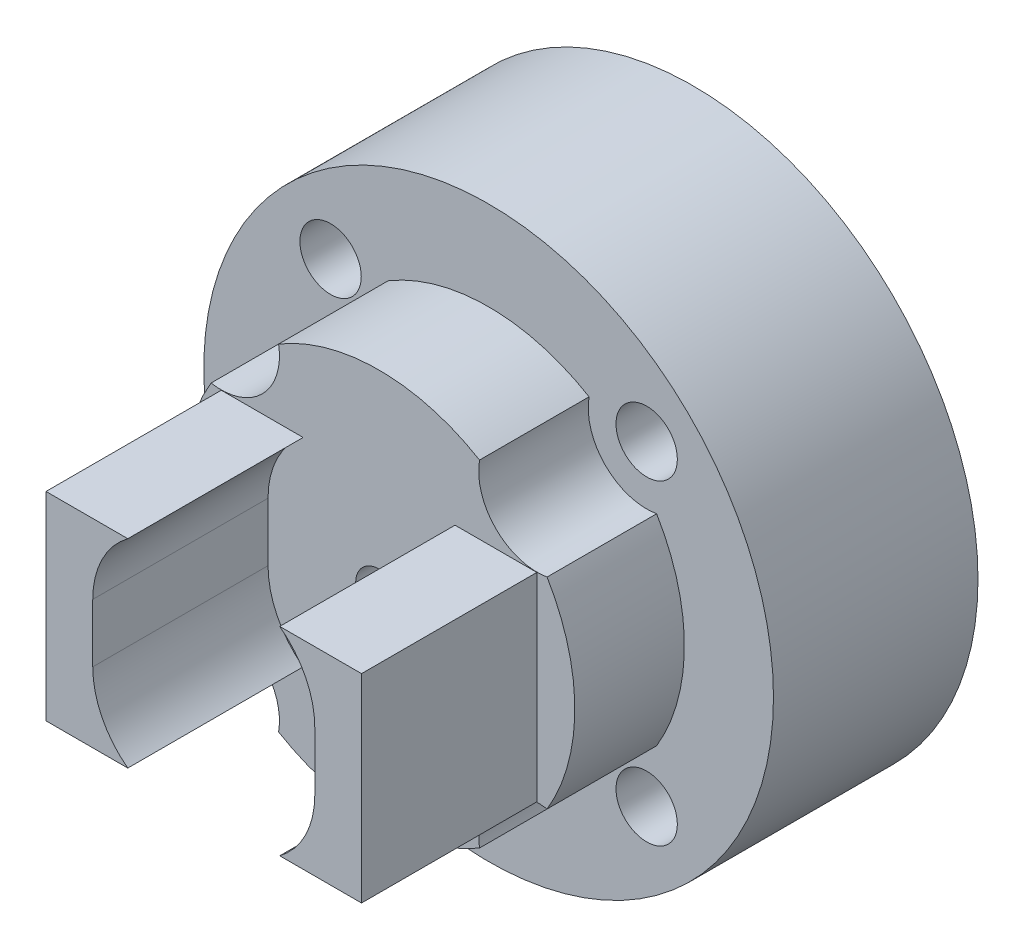
from build123d import *

# Parameters (mm, degrees)
SKIZZE1_R                       = 6.7
AUFSATZ_LINEAR_AUSTRAGEN1_DEPTH = 3.75
SKIZZE1_7_R                     = 9.75
SKIZZE1_7_R_2                   = 3.55
AUFSATZ_LINEAR_AUSTRAGEN2_DEPTH = 7
SKIZZE5_R                       = 1.05
SCHNITT_LINEAR_AUSTRAGEN1_DEPTH = 11.75
SKIZZE5_3_R                     = 2
SKIZZE5_3_R_2                   = 1.05
SCHNITT_LINEAR_AUSTRAGEN2_DEPTH = 3.75
FASE1_SIZE                      = 0.3
AUFSATZ_LINEAR_AUSTRAGEN4_DEPTH = 6
M2_GEWINDEBOHRUNG1_D            = 1.6


with BuildPart() as part:
    # Skizze1 → Aufsatz-Linear austragen1 (new body)
    with BuildSketch(Plane.XY):
        Circle(SKIZZE1_R)
    extrude(amount=AUFSATZ_LINEAR_AUSTRAGEN1_DEPTH)

    # Skizze1_7 → Aufsatz-Linear austragen2 (add)
    with BuildSketch(Plane.XY):
        Circle(SKIZZE1_7_R)
        Circle(SKIZZE1_7_R_2, mode=Mode.SUBTRACT)
    extrude(amount=-AUFSATZ_LINEAR_AUSTRAGEN2_DEPTH)

    # Skizze5 → Schnitt-Linear austragen1 (cut, through all)
    with BuildSketch(Plane.XY.offset(3.75)):
        with Locations((5.409366876, 5.409366876)):
            Circle(SKIZZE5_R)
        with Locations((5.409366876, -5.409366876)):
            Circle(SKIZZE5_R)
        with Locations((-5.409366876, -5.409366876)):
            Circle(SKIZZE5_R)
        with Locations((-5.409366876, 5.409366876)):
            Circle(SKIZZE5_R)
    extrude(amount=-SCHNITT_LINEAR_AUSTRAGEN1_DEPTH, mode=Mode.SUBTRACT)

    # Skizze5_3 → Schnitt-Linear austragen2 (cut)
    with BuildSketch(Plane.XY.offset(3.75)):
        with Locations((-5.409366876, 5.409366876)):
            Circle(SKIZZE5_3_R)
        with Locations((-5.409366876, 5.409366876)):
            Circle(SKIZZE5_3_R_2, mode=Mode.SUBTRACT)
        with Locations((5.409366876, 5.409366876)):
            Circle(SKIZZE5_3_R)
        with Locations((5.409366876, 5.409366876)):
            Circle(SKIZZE5_3_R_2, mode=Mode.SUBTRACT)
        with Locations((5.409366876, -5.409366876)):
            Circle(SKIZZE5_3_R)
        with Locations((5.409366876, -5.409366876)):
            Circle(SKIZZE5_3_R_2, mode=Mode.SUBTRACT)
        with Locations((-5.409366876, -5.409366876)):
            Circle(SKIZZE5_3_R)
        with Locations((-5.409366876, -5.409366876)):
            Circle(SKIZZE5_3_R_2, mode=Mode.SUBTRACT)
    extrude(amount=-SCHNITT_LINEAR_AUSTRAGEN2_DEPTH, mode=Mode.SUBTRACT)

    # Fase1
    fase1_edges = [part.edges().sort_by_distance(p)[0] for p in [
        (-3.55, 0, -7),
    ]]
    chamfer(fase1_edges, length=FASE1_SIZE)

    # Skizze7 → Aufsatz-Linear austragen4 (add)
    with BuildSketch(Plane.XY.offset(3.75)):
        with BuildLine():
            Line((-5.4, 3.4), (-2.6, 3.4))
            ThreePointArc((-2.6, 3.4), (-3.483281573, 2.341640786), (-3.8, 1))
            Line((-3.8, 1), (-3.8, -1))
            ThreePointArc((-3.8, -1), (-3.483281573, -2.341640786), (-2.6, -3.4))
            Line((-2.6, -3.4), (-5.4, -3.4))
            Line((-5.4, -3.4), (-5.4, 3.4))
        make_face()
        with BuildLine():
            Line((5.4, -3.4), (2.6, -3.4))
            ThreePointArc((2.6, -3.4), (3.483281573, -2.341640786), (3.8, -1))
            Line((3.8, -1), (3.8, 1))
            ThreePointArc((3.8, 1), (3.483281573, 2.341640786), (2.6, 3.4))
            Line((2.6, 3.4), (5.4, 3.4))
            Line((5.4, 3.4), (5.4, -3.4))
        make_face()
    extrude(amount=AUFSATZ_LINEAR_AUSTRAGEN4_DEPTH)

    # M2 Gewindebohrung1 (through all)
    with Locations(Plane.XY.offset(3.75)):
        with Locations((0, 0)):
            Hole(M2_GEWINDEBOHRUNG1_D / 2)


solid = part.part
